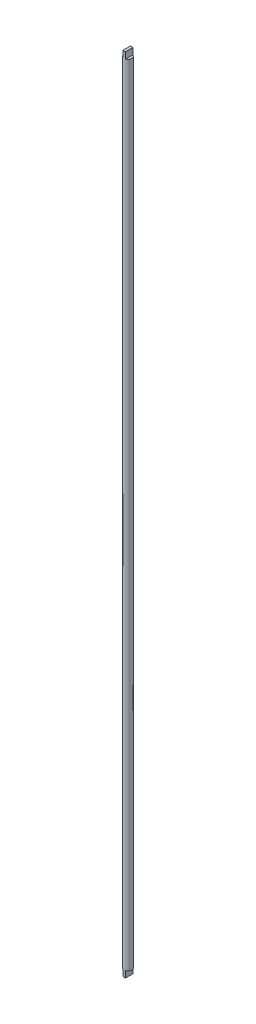
from build123d import *

# Parameters (mm, degrees)
SKETCH1_R           = 3
BOSS_EXTRUDE1_DEPTH = 616.37
BOSS_EXTRUDE3_DEPTH = 5
SKETCH4_W           = 2
SKETCH4_H           = 5.65685425
BOSS_EXTRUDE4_DEPTH = 641.64
SKETCH5_W           = 2
SKETCH5_H           = 5.65685425
CUT_EXTRUDE2_DEPTH  = 15.27


with BuildPart() as part:
    # Sketch1 → Boss-Extrude1 (new body)
    with BuildSketch(Plane(origin=(0, 0, 0), x_dir=(1, 0, 0), z_dir=(0, 1, 0))):
        Circle(SKETCH1_R)
    extrude(amount=BOSS_EXTRUDE1_DEPTH)

    # Sketch2 → Boss-Extrude3 (add)
    with BuildSketch(Plane(origin=(0, 616.37, 0), x_dir=(1, 0, 0), z_dir=(0, 1, 0))):
        with BuildLine():
            ThreePointArc((-1, -2.828427125), (-0.507305936, -2.956795679), (0, -3))
            ThreePointArc((0, -3), (0.507305936, -2.956795679), (1, -2.828427125))
            Line((1, -2.828427125), (1, 2.828427125))
            ThreePointArc((1, 2.828427125), (0.507305936, 2.956795679), (0, 3))
            ThreePointArc((0, 3), (-0.507305936, 2.956795679), (-1, 2.828427125))
            Line((-1, 2.828427125), (-1, -2.828427125))
        make_face()
    extrude(amount=BOSS_EXTRUDE3_DEPTH)

    # Sketch4 → Boss-Extrude4 (add)
    with BuildSketch(Plane(origin=(0, 621.37, 0), x_dir=(1, 0, 0), z_dir=(0, 1, 0))):
        Rectangle(SKETCH4_W, SKETCH4_H)
        with BuildLine():
            Line((-1, -2.828427125), (1, -2.828427125))
            ThreePointArc((1, -2.828427125), (0, -3), (-1, -2.828427125))
        make_face()
        with BuildLine():
            Line((-1, 2.828427125), (1, 2.828427125))
            ThreePointArc((1, 2.828427125), (0, 3), (-1, 2.828427125))
        make_face()
    extrude(amount=-BOSS_EXTRUDE4_DEPTH)

    # Sketch5 → Cut-Extrude2 (cut)
    with BuildSketch(Plane.XZ.offset(20.27)):
        with BuildLine():
            Line((-1, -2.828427125), (1, -2.828427125))
            ThreePointArc((1, -2.828427125), (0, -3), (-1, -2.828427125))
        make_face()
        Rectangle(SKETCH5_W, SKETCH5_H)
        with BuildLine():
            Line((-1, 2.828427125), (1, 2.828427125))
            ThreePointArc((1, 2.828427125), (0, 3), (-1, 2.828427125))
        make_face()
    extrude(amount=-CUT_EXTRUDE2_DEPTH, mode=Mode.SUBTRACT)


solid = part.part
